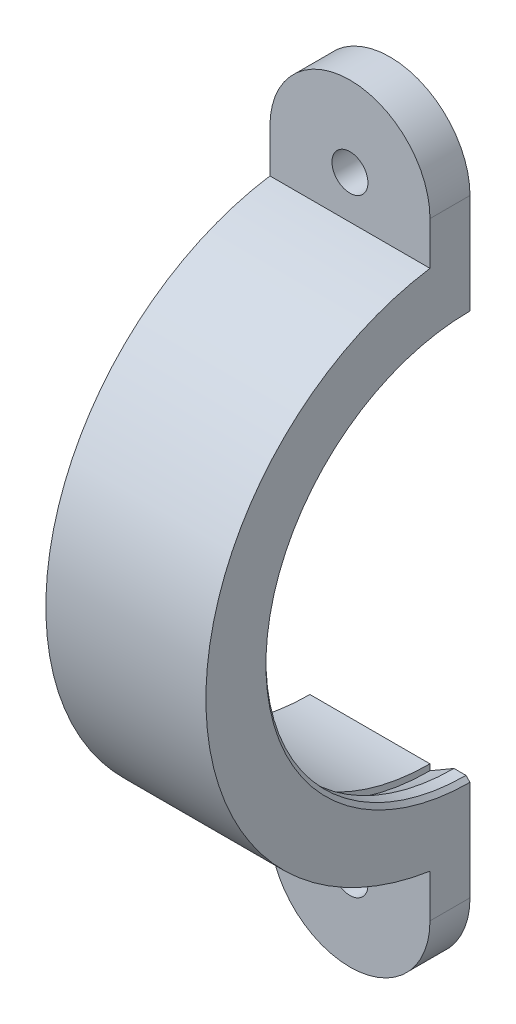
from build123d import *

# Parameters (mm, degrees)
REVOLVE1_ANGLE      = 180
BOSS_EXTRUDE3_DEPTH = 5
BOSS_EXTRUDE4_DEPTH = 5
SKETCH17_R          = 2.2479
CUT_EXTRUDE1_DEPTH  = 34
CHAMFER1_SIZE       = 0.5


with BuildPart() as part:
    # Sketch1 → Revolve1 (revolve)
    with BuildSketch(Plane.XY):
        Polygon((15, 26), (15, 26.75), (18, 25), (20, 25), (20, 33), (0, 33), (0, 26), align=None)
    revolve(axis=Axis((0, 0, 0), (1, 0, 0)), revolution_arc=REVOLVE1_ANGLE)

    # Sketch9 → Boss-Extrude3 (add)
    with BuildSketch(Plane(origin=(0, 0, 0), x_dir=(-1, 0, 0), z_dir=(0, 0, -1))):
        with BuildLine():
            Line((-20, 29), (0, 29))
            Line((0, 29), (0, 38))
            ThreePointArc((0, 38), (-10, 48), (-20, 38))
            Line((-20, 38), (-20, 29))
        make_face()
    extrude(amount=-BOSS_EXTRUDE3_DEPTH)

    # Sketch11 → Boss-Extrude4 (add)
    with BuildSketch(Plane(origin=(0, 0, 0), x_dir=(-1, 0, 0), z_dir=(0, 0, -1))):
        with BuildLine():
            Line((-20, -29), (0, -29))
            Line((0, -29), (0, -38))
            ThreePointArc((0, -38), (-10, -48), (-20, -38))
            Line((-20, -38), (-20, -29))
        make_face()
    extrude(amount=-BOSS_EXTRUDE4_DEPTH)

    # Sketch17 → Cut-Extrude1 (cut, through all)
    with BuildSketch(Plane(origin=(0, 0, 0), x_dir=(-1, 0, 0), z_dir=(0, 0, -1))):
        with Locations((-10, 38)):
            Circle(SKETCH17_R)
        with Locations((-10, -38)):
            Circle(SKETCH17_R)
    extrude(amount=-CUT_EXTRUDE1_DEPTH, mode=Mode.SUBTRACT)

    # Chamfer1
    chamfer1_edges = [part.edges().sort_by_distance(p)[0] for p in [
        (20, 0, 25),
    ]]
    chamfer(chamfer1_edges, length=CHAMFER1_SIZE)


solid = part.part
